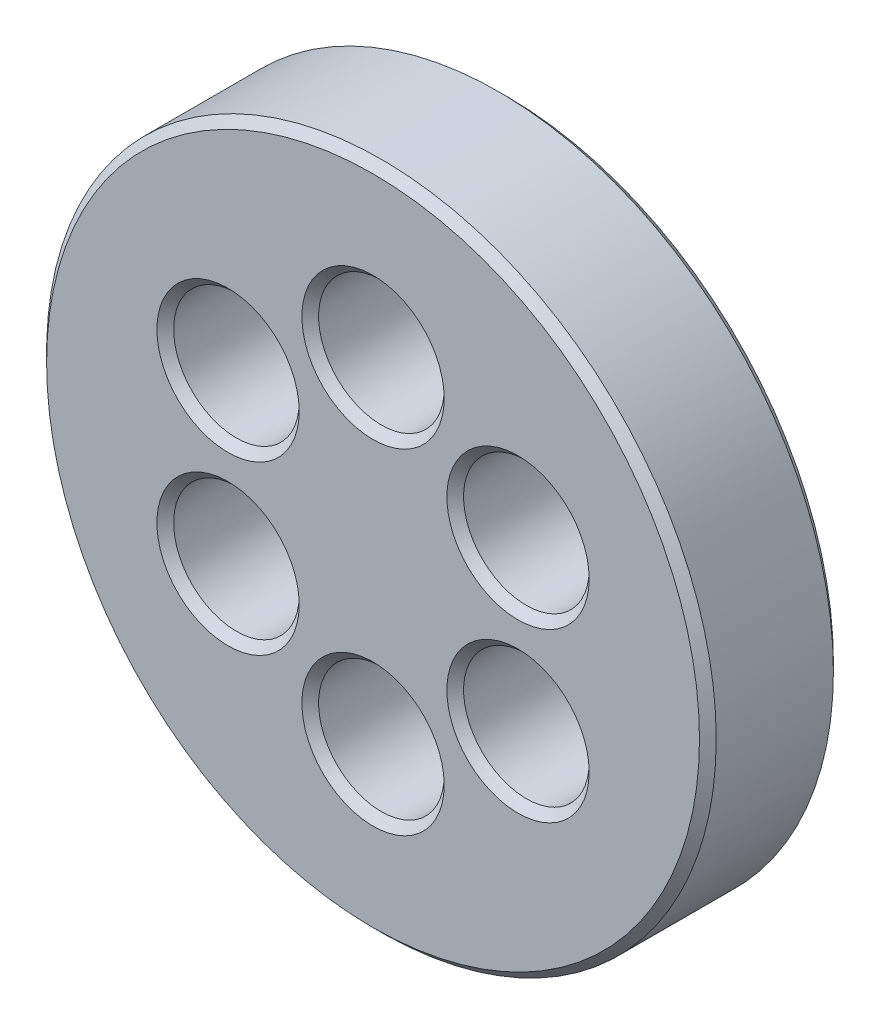
from build123d import *

# Parameters (mm, degrees)
SKETCH3_R           = 20
BOSS_EXTRUDE1_DEPTH = 8
SKETCH4_R           = 3.75
CUT_EXTRUDE1_DEPTH  = 8
CIRPATTERN1_COUNT   = 6
CHAMFER1_SIZE       = 0.5


with BuildPart() as part:
    # Sketch3 → Boss-Extrude1 (new body)
    with BuildSketch(Plane.XY):
        Circle(SKETCH3_R)
    extrude(amount=BOSS_EXTRUDE1_DEPTH)

    # Sketch4 → Cut-Extrude1 (cut)
    with BuildSketch(Plane.XY.offset(8)):
        with Locations((0, 10)):
            Circle(SKETCH4_R)
    cut_extrude1 = extrude(amount=-CUT_EXTRUDE1_DEPTH, mode=Mode.SUBTRACT)

    # CirPattern1: Cut-Extrude1 ×6 about axis
    cirpattern1_axis = Axis((0, 0, 0), (0, 0, 1))
    for i in range(1, CIRPATTERN1_COUNT):
        add(cut_extrude1.rotate(cirpattern1_axis, i * 360 / CIRPATTERN1_COUNT), mode=Mode.SUBTRACT)

    # Chamfer1
    chamfer1_edges = [part.edges().sort_by_distance(p)[0] for p in [
        (-10.535254038, 1.752404736, 0),
        (-10.535254038, 1.752404736, 8),
        (-6.785254038, -8.247595264, 0),
        (-6.785254038, -8.247595264, 8),
        (3.75, -10, 0),
        (-20, 0, 0),
        (3.75, -10, 8),
        (10.535254038, -1.752404736, 0),
        (10.535254038, -1.752404736, 8),
        (6.785254038, 8.247595264, 0),
        (6.785254038, 8.247595264, 8),
        (-20, 0, 8),
        (-3.75, 10, 0),
        (-3.75, 10, 8),
    ]]
    chamfer(chamfer1_edges, length=CHAMFER1_SIZE)


solid = part.part
